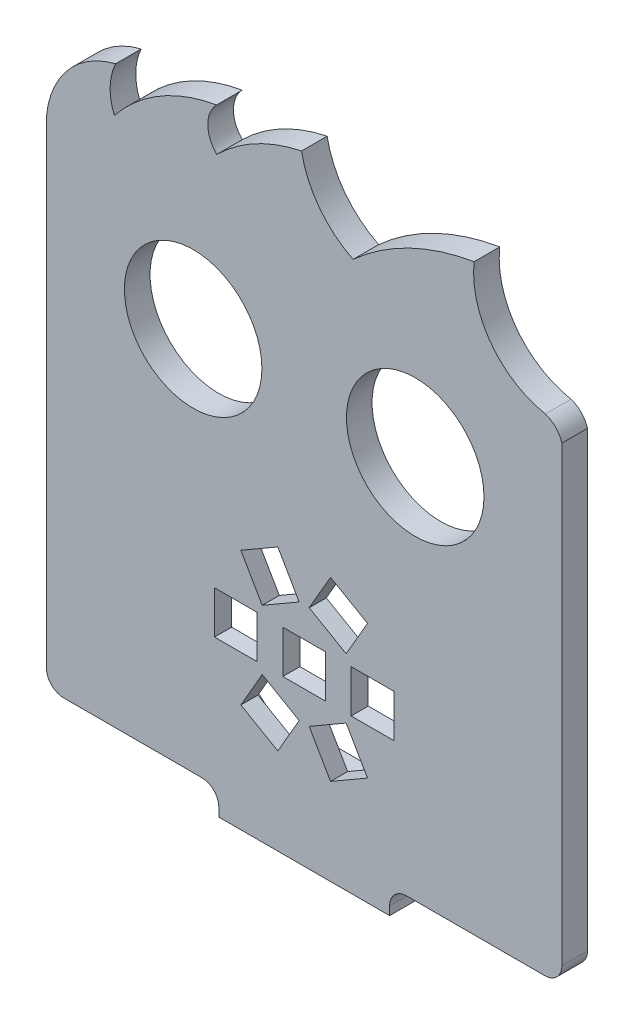
from build123d import *

# Parameters (mm, degrees)
MODEL_R                 = 8.05
MODEL_W                 = 5
MODEL_H                 = 5
SALIENTE_EXTRUIR1_DEPTH = 3
CROQUIS3_W              = 20
CROQUIS3_H              = 3
SALIENTE_EXTRUIR2_DEPTH = 8
CROQUIS4_R              = 1.5
CORTAR_EXTRUIR1_DEPTH   = 3
CROQUIS5_R              = 2.25
CORTAR_EXTRUIR2_DEPTH   = 1
REDONDEO1_R             = 2
CROQUIS6_R              = 12
CORTAR_EXTRUIR3_DEPTH   = 1


with BuildPart() as part:
    # Model → Saliente-Extruir1 (new body)
    with BuildSketch(Plane.XY):
        with BuildLine():
            Line((50.698959582, -56.020997464), (70.698959582, -56.020997464))
            Line((70.698959582, -56.020997464), (70.698959582, -55.020997464))
            ThreePointArc((70.698959582, -55.020997464), (71.28474602, -53.606783901), (72.698959582, -53.020997464))
            Line((72.698959582, -53.020997464), (88.870799912, -53.020997464))
            ThreePointArc((88.870799912, -53.020997464), (90.285013474, -52.435211026), (90.870799912, -51.020997464))
            Line((90.870799912, -51.020997464), (90.870799912, 1.979002536))
            ThreePointArc((90.870799912, 1.979002536), (90.150187884, 3.212884764), (88.940527152, 3.973455574))
            ThreePointArc((88.940527152, 3.973455574), (82.556801864, 7.967186508), (80.592387516, 15.236499516))
            ThreePointArc((80.592387516, 15.236499516), (73.016137183, 12.831206377), (66.424253692, 8.389126209))
            ThreePointArc((66.424253692, 8.389126209), (62.464845981, 11.66270114), (60.387431279, 16.361376528))
            ThreePointArc((60.387431279, 16.361376528), (55.039384462, 14.426569266), (50.461877073, 11.051438157))
            ThreePointArc((50.461877073, 11.051438157), (49.41482724, 13.546636971), (50.438823204, 16.051385009))
            ThreePointArc((50.438823204, 16.051385009), (43.800023098, 13.634815248), (38.471226177, 8.99613013))
            ThreePointArc((38.471226177, 8.99613013), (37.976525569, 11.673196605), (38.618250464, 14.318872844))
            ThreePointArc((38.618250464, 14.318872844), (33.077419178, 10.94136051), (30.527119253, 4.974420659))
            Line((30.527119253, 4.974420659), (30.527119253, -51.020997464))
            ThreePointArc((30.527119253, -51.020997464), (31.112905691, -52.435211026), (32.527119253, -53.020997464))
            Line((32.527119253, -53.020997464), (48.698959582, -53.020997464))
            ThreePointArc((48.698959582, -53.020997464), (50.113173145, -53.606783901), (50.698959582, -55.020997464))
            Line((50.698959582, -55.020997464), (50.698959582, -56.020997464))
        make_face()
        with Locations((47.698959583, -8.020997464)):
            Circle(MODEL_R, mode=Mode.SUBTRACT)
        with Locations((73.698959582, -8.020997464)):
            Circle(MODEL_R, mode=Mode.SUBTRACT)
        Polygon((53.283896073, -43.364264203), (57.614023092, -45.864264203), (60.114023092, -41.534137185), (55.783896073, -39.034137185), align=None, mode=Mode.SUBTRACT)
        Polygon((63.783896073, -45.864264204), (68.114023092, -43.364264204), (65.614023092, -39.034137185), (61.283896073, -41.534137185), align=None, mode=Mode.SUBTRACT)
        with Locations((68.698959582, -35.520997464)):
            Rectangle(MODEL_W, MODEL_H, mode=Mode.SUBTRACT)
        Polygon((68.114023092, -27.677730724), (63.783896073, -25.177730724), (61.283896073, -29.507857743), (65.614023092, -32.007857743), align=None, mode=Mode.SUBTRACT)
        Polygon((57.614023092, -25.177730724), (53.283896073, -27.677730724), (55.783896073, -32.007857743), (60.114023092, -29.507857743), align=None, mode=Mode.SUBTRACT)
        with Locations((52.698959582, -35.520997464)):
            Rectangle(MODEL_W, MODEL_H, mode=Mode.SUBTRACT)
        with Locations((60.698959582, -35.520997464)):
            Rectangle(MODEL_W, MODEL_H, mode=Mode.SUBTRACT)
    extrude(amount=SALIENTE_EXTRUIR1_DEPTH)

    # Croquis3 → Saliente-Extruir2 (add)
    with BuildSketch(Plane(origin=(0, 0, 0), x_dir=(-1, 0, 0), z_dir=(0, 0, -1))):
        with Locations((-60.698959582, -54.520997464)):
            Rectangle(CROQUIS3_W, CROQUIS3_H)
    extrude(amount=SALIENTE_EXTRUIR2_DEPTH)

    # Croquis4 → Cortar-Extruir1 (cut)
    with BuildSketch(Plane(origin=(0, -53.020997464, 0), x_dir=(1, 0, 0), z_dir=(0, 1, 0))):
        with Locations((66.698959582, 3.5)):
            Circle(CROQUIS4_R)
        with Locations((54.698959582, 3.5)):
            Circle(CROQUIS4_R)
    extrude(amount=-CORTAR_EXTRUIR1_DEPTH, mode=Mode.SUBTRACT)

    # Croquis5 → Cortar-Extruir2 (cut)
    with BuildSketch(Plane(origin=(0, -53.020997464, 0), x_dir=(1, 0, 0), z_dir=(0, 1, 0))):
        with Locations((66.698959582, 3.5)):
            Circle(CROQUIS5_R)
        with Locations((54.698959582, 3.5)):
            Circle(CROQUIS5_R)
    extrude(amount=-CORTAR_EXTRUIR2_DEPTH, mode=Mode.SUBTRACT)

    # Redondeo1
    redondeo1_edges = [part.edges().sort_by_distance(p)[0] for p in [
        (50.698959582, -54.520997464, -8),
        (70.698959582, -54.520997464, -8),
    ]]
    fillet(redondeo1_edges, radius=REDONDEO1_R)

    # Croquis6 → Cortar-Extruir3 (cut)
    with BuildSketch(Plane(origin=(0, 0, 0), x_dir=(-1, 0, 0), z_dir=(0, 0, -1))):
        with Locations((-60.698959582, -35.520997464)):
            Circle(CROQUIS6_R)
    extrude(amount=-CORTAR_EXTRUIR3_DEPTH, mode=Mode.SUBTRACT)


solid = part.part
